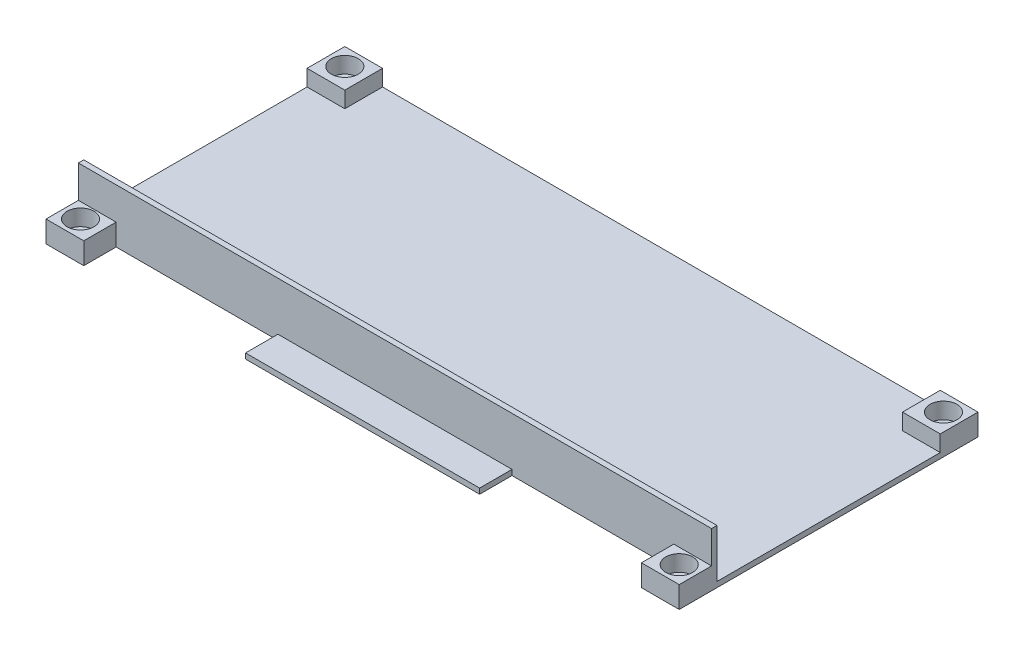
from build123d import *

# Parameters (mm, degrees)
SKETCH1_W           = 117.4
SKETCH1_H           = 55.4
BOSS_EXTRUDE1_DEPTH = 1
SKETCH2_W           = 7
SKETCH2_H           = 7
BOSS_EXTRUDE2_DEPTH = 3
SKETCH3_R           = 1.35
CUT_EXTRUDE1_DEPTH  = 5
SKETCH7_W           = 30
SKETCH7_H           = 6
CUT_EXTRUDE5_DEPTH  = 5
SKETCH9_R           = 2.5
CUT_EXTRUDE6_DEPTH  = 3
SKETCH10_W          = 117.4
SKETCH10_H          = 1
BOSS_EXTRUDE3_DEPTH = 9


with BuildPart() as part:
    # Sketch1 → Boss-Extrude1 (new body)
    with BuildSketch(Plane(origin=(0, 0, 0), x_dir=(1, 0, 0), z_dir=(0, 1, 0))):
        Rectangle(SKETCH1_W, SKETCH1_H)
    extrude(amount=BOSS_EXTRUDE1_DEPTH)

    # Sketch2 → Boss-Extrude2 (add)
    with BuildSketch(Plane(origin=(0, 1, 0), x_dir=(1, 0, 0), z_dir=(0, 1, 0))):
        with Locations((55.2, 24.2)):
            Rectangle(SKETCH2_W, SKETCH2_H)
        with Locations((-55.2, 24.2)):
            Rectangle(SKETCH2_W, SKETCH2_H)
        with Locations((55.2, -24.2)):
            Rectangle(SKETCH2_W, SKETCH2_H)
        with Locations((-55.2, -24.2)):
            Rectangle(SKETCH2_W, SKETCH2_H)
    extrude(amount=BOSS_EXTRUDE2_DEPTH)

    # Sketch3 → Cut-Extrude1 (cut, through all)
    with BuildSketch(Plane(origin=(0, 4, 0), x_dir=(1, 0, 0), z_dir=(0, 1, 0))):
        with Locations((-55.5, 24.5)):
            Circle(SKETCH3_R)
        with Locations((55.5, 24.5)):
            Circle(SKETCH3_R)
        with Locations((55.5, -24.5)):
            Circle(SKETCH3_R)
        with Locations((-55.5, -24.5)):
            Circle(SKETCH3_R)
    extrude(amount=-CUT_EXTRUDE1_DEPTH, mode=Mode.SUBTRACT)

    # Sketch7 → Cut-Extrude5 (cut, through all)
    with BuildSketch(Plane.XZ):
        with Locations((36.7, 24.7)):
            Rectangle(SKETCH7_W, SKETCH7_H)
        with Locations((-36.7, 24.7)):
            Rectangle(SKETCH7_W, SKETCH7_H)
    extrude(amount=-CUT_EXTRUDE5_DEPTH, mode=Mode.SUBTRACT)

    # Sketch9 → Cut-Extrude6 (cut)
    with BuildSketch(Plane(origin=(0, 4, 0), x_dir=(1, 0, 0), z_dir=(0, 1, 0))):
        with Locations((-55.5, 24.5)):
            Circle(SKETCH9_R)
        with Locations((55.5, 24.5)):
            Circle(SKETCH9_R)
        with Locations((55.5, -24.5)):
            Circle(SKETCH9_R)
        with Locations((-55.5, -24.5)):
            Circle(SKETCH9_R)
    extrude(amount=-CUT_EXTRUDE6_DEPTH, mode=Mode.SUBTRACT)

    # Sketch10 → Boss-Extrude3 (add)
    with BuildSketch(Plane(origin=(0, 1, 0), x_dir=(1, 0, 0), z_dir=(0, 1, 0))):
        with Locations((0, -21.2)):
            Rectangle(SKETCH10_W, SKETCH10_H)
    extrude(amount=BOSS_EXTRUDE3_DEPTH)


solid = part.part
